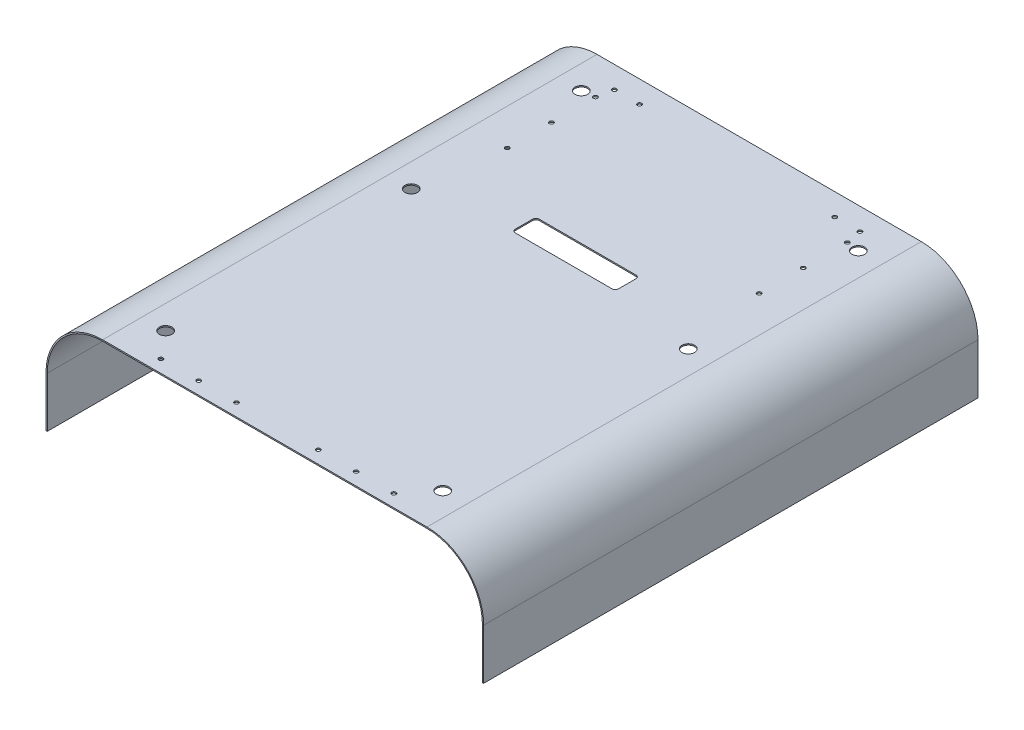
from build123d import *

# Parameters (mm, degrees)
SURFACE_EXTRUDE1_1_DEPTH   = 785
THICKEN1_T2                = 2
SKETCH2_R                  = 10
CUT_EXTRUDE1_DEPTH         = 171
SKETCH3_R                  = 10
CUT_EXTRUDE2_DEPTH         = 171
MIRROR2_COPY_1_SKETCH_R    = 10
MIRROR2_COPY_1_DEPTH       = 171
CUT_EXTRUDE3_DEPTH         = 171
F_6_6_6_6_DIAMETER_SLOT1_D = 6.6


with BuildPart() as body_1:
    # Surface-Extrude1: a surface, the sketch's curves swept straight by 785 mm
    with BuildLine(Plane.XY, mode=Mode.PRIVATE) as surface_extrude1_1_path:
        Line((-347.5, -170), (-347.5, -90))
        ThreePointArc((-347.5, -90), (-321.139610307, -26.360389693), (-257.5, 0))
        Line((-257.5, 0), (257.5, 0))
        ThreePointArc((257.5, 0), (321.139610307, -26.360389693), (347.5, -90))
        Line((347.5, -90), (347.5, -170))
    surface_extrude1_1 = Shell.extrude(surface_extrude1_1_path.wire(), (0 * SURFACE_EXTRUDE1_1_DEPTH, 0 * SURFACE_EXTRUDE1_1_DEPTH, 1 * SURFACE_EXTRUDE1_1_DEPTH))
    add(Solid.thicken(surface_extrude1_1, -THICKEN1_T2))

    # Sketch2 → Cut-Extrude1 (cut, through all)
    with BuildSketch(Plane(origin=(0, 0, 0), x_dir=(1, 0, 0), z_dir=(0, 1, 0))):
        with Locations(Location((220, -62.5, 0), (0, 0, 180))):  # turned: the seam where the file's is
            Circle(SKETCH2_R)
    cut_extrude1 = extrude(amount=-CUT_EXTRUDE1_DEPTH, mode=Mode.SUBTRACT)

    # Mirror1: Cut-Extrude1 across plane
    add(cut_extrude1.mirror(Plane(origin=(0, 0, 392.5), x_dir=(1, 0, 0), z_dir=(0, 0, -1))), mode=Mode.SUBTRACT)

    # Sketch3 → Cut-Extrude2 (cut, through all)
    with BuildSketch(Plane(origin=(0, 0, 0), x_dir=(1, 0, 0), z_dir=(0, 1, 0))):
        with Locations(Location((220, -332.5, 0), (0, 0, 180))):  # turned: the seam where the file's is
            Circle(SKETCH3_R)
    cut_extrude2 = extrude(amount=-CUT_EXTRUDE2_DEPTH, mode=Mode.SUBTRACT)

    # Mirror2: Cut-Extrude2, Cut-Extrude1 across plane
    add(cut_extrude2.mirror(Plane.ZY), mode=Mode.SUBTRACT)
    add(cut_extrude1.mirror(Plane.ZY), mode=Mode.SUBTRACT)

    # Mirror2 copy 1 sketch → Mirror2 copy 1 (cut, through all)
    with BuildSketch(Plane(origin=(0, 0, 785), x_dir=(-1, 0, 0), z_dir=(0, 1, 0))):
        with Locations(Location((220, -62.5, 0), (0, 0, 180))):  # turned: the seam where the file's is
            Circle(MIRROR2_COPY_1_SKETCH_R)
    extrude(amount=-MIRROR2_COPY_1_DEPTH, mode=Mode.SUBTRACT)

    # Sketch4 → Cut-Extrude3 (cut, through all)
    with BuildSketch(Plane(origin=(0, 0, 0), x_dir=(1, 0, 0), z_dir=(0, 1, 0))):
        with BuildLine():
            Line((77, -310.5), (-77, -310.5))
            ThreePointArc((-77, -310.5), (-80.535533906, -309.035533906), (-82, -305.5))
            Line((-82, -305.5), (-82, -277.5))
            ThreePointArc((-82, -277.5), (-80.535533906, -273.964466094), (-77, -272.5))
            Line((-77, -272.5), (77, -272.5))
            ThreePointArc((77, -272.5), (80.535533906, -273.964466094), (82, -277.5))
            Line((82, -277.5), (82, -305.5))
            ThreePointArc((82, -305.5), (80.535533906, -309.035533906), (77, -310.5))
        make_face()
    extrude(amount=-CUT_EXTRUDE3_DEPTH, mode=Mode.SUBTRACT)

    # Ø6.6 (6.6) Diameter Slot1 (through all)
    with Locations(Plane(origin=(0, -2, 0), x_dir=(-1, 0, 0), z_dir=(0, -1, 0))):
        with Locations((185, -765), (125, -765), (65, -765), (-65, -765), (-125, -765), (-185, -765), (200, -200), (200, -130), (155, -35), (195, -35), (200, -60), (-195, -35), (-155, -35), (-200, -60), (-200, -130), (-200, -200)):
            Hole(F_6_6_6_6_DIAMETER_SLOT1_D / 2)


solid = body_1.part
